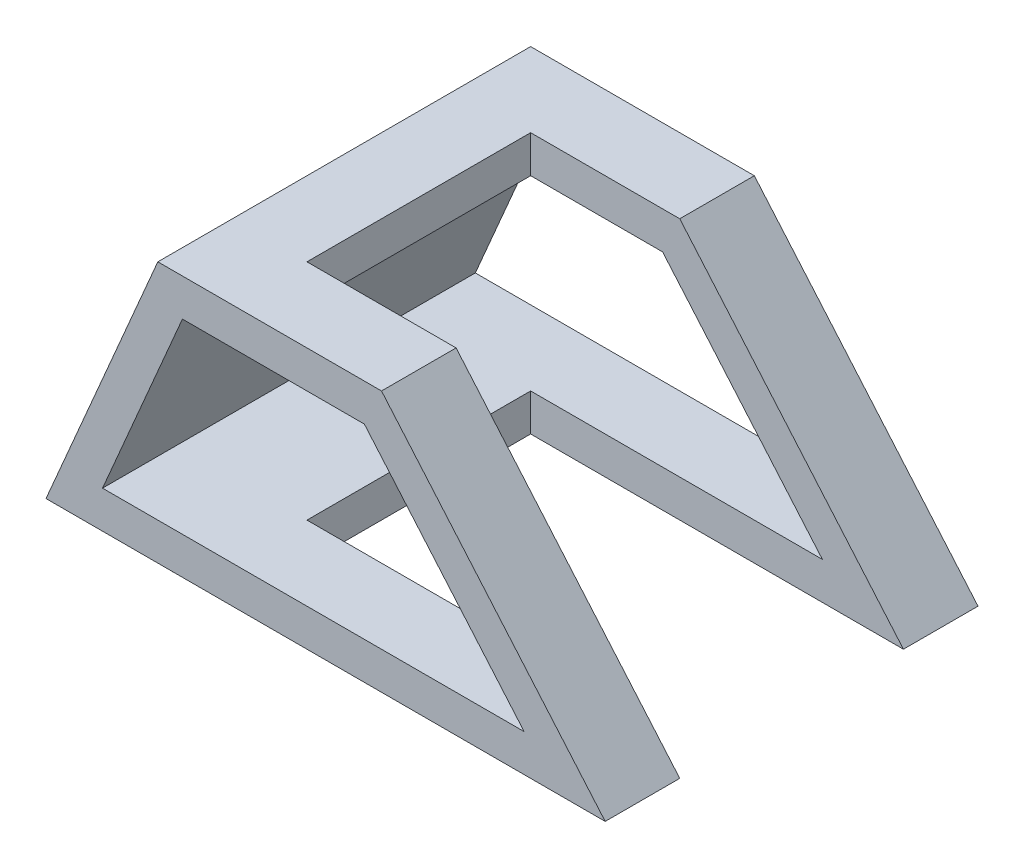
from build123d import *

# Parameters (mm, degrees)
BOSS_EXTRU_2_DEPTH      = 100
ENL_V_MAT_EXTRU_1_REACH = 72
ESQUISSE2_W             = 100
ESQUISSE2_H             = 60


with BuildPart() as part:
    # Esquisse1 → Boss.-Extru.2 (new body)
    with BuildSketch(Plane.XY):
        Polygon((0, 0), (150, 0), (90, 70), (30, 70), align=None)
        Polygon((36.59396158, 60), (15.165390151, 10), (128.257793632, 10), (85.400650775, 60), align=None, mode=Mode.SUBTRACT)
    extrude(amount=-BOSS_EXTRU_2_DEPTH)

    # Esquisse2 → Enlèv. mat.-Extru.1 (cut, up to next)
    with BuildSketch(Plane(origin=(0, 70, 0), x_dir=(1, 0, 0), z_dir=(0, 1, 0)), mode=Mode.PRIVATE) as enl_v_mat_extru_1_sk1:
        with Locations((100, 50)):
            Rectangle(ESQUISSE2_W, ESQUISSE2_H)
    enl_v_mat_extru_1_tool1 = extrude(enl_v_mat_extru_1_sk1.sketch, amount=-ENL_V_MAT_EXTRU_1_REACH, mode=Mode.PRIVATE) & part.part
    add(enl_v_mat_extru_1_tool1.solids().sort_by_distance((100, 70, -50))[0], mode=Mode.SUBTRACT)


solid = part.part
